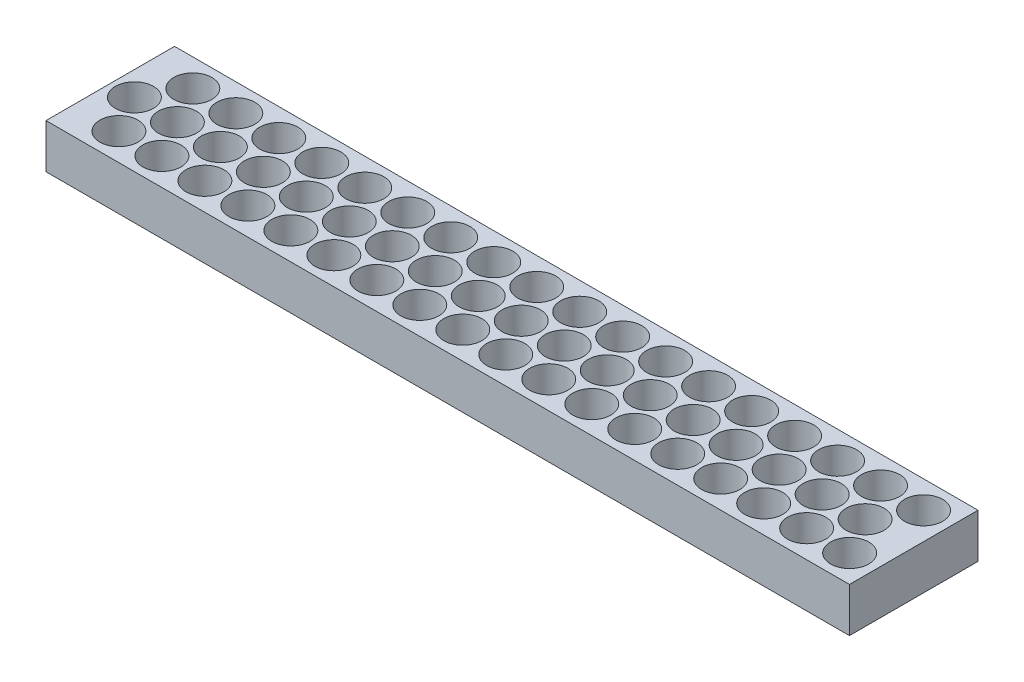
from build123d import *

# Parameters (mm, degrees)
SKETCH1_W           = 635
SKETCH1_H           = 101.6
BOSS_EXTRUDE1_DEPTH = 35.052
SKETCH1_3_R         = 15.08125
CUT_EXTRUDE3_DEPTH  = 600.766589608
LPATTERN1_COUNT     = 18
LPATTERN1_PITCH     = 33.9725


with BuildPart() as part:
    # Sketch1 → Boss-Extrude1 (new body)
    with BuildSketch(Plane(origin=(0, 0, 0), x_dir=(1, 0, 0), z_dir=(0, 1, 0))):
        with Locations((-279.0825, 0)):
            Rectangle(SKETCH1_W, SKETCH1_H)
    extrude(amount=BOSS_EXTRUDE1_DEPTH)

    # Sketch1_3 → Cut-Extrude3 (cut, symmetric)
    with BuildSketch(Plane(origin=(0, 0, 0), x_dir=(1, 0, 0), z_dir=(0, 1, 0))):
        Circle(SKETCH1_3_R)
        with Locations((16.98625, 29.21)):
            Circle(SKETCH1_3_R)
        with Locations((16.98625, -29.21)):
            Circle(SKETCH1_3_R)
    cut_extrude3 = extrude(amount=CUT_EXTRUDE3_DEPTH, both=True, mode=Mode.SUBTRACT)

    # LPattern1: Cut-Extrude3 ×18
    with Locations(*[(-i * LPATTERN1_PITCH, 0, 0) for i in range(1, LPATTERN1_COUNT)]):
        add(cut_extrude3, mode=Mode.SUBTRACT)


solid = part.part
